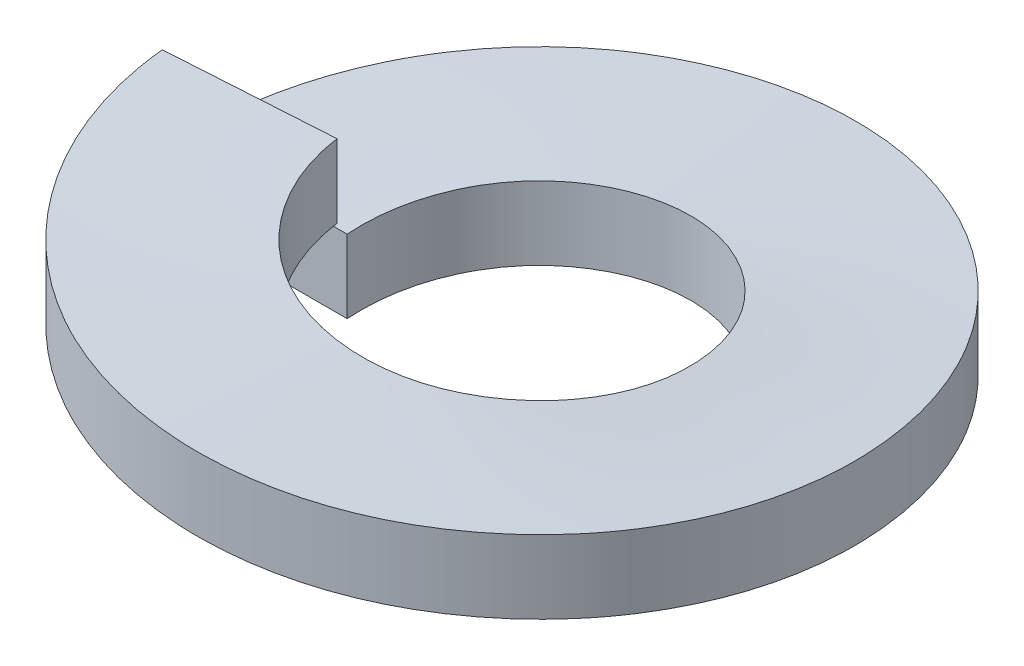
from build123d import *

# Parameters (mm, degrees)
SWEEP1_PITCH       = 0.615757576
SWEEP1_HEIGHT      = 0.6096
SWEEP1_RADIUS      = 2.286
SWEEP1_START_ANGLE = -90
SKETCH1_W          = 1.143
SKETCH1_H          = 0.508


with BuildPart() as part:
    # Sweep1: sweep along a helix
    with BuildLine() as sweep1_path:
        add(Helix(SWEEP1_PITCH, SWEEP1_HEIGHT, SWEEP1_RADIUS, center=(0, 0, 0), direction=(0, 1, 0), lefthand=True, mode=Mode.PRIVATE).rotate(Axis((0, 0, 0), (0, 1, 0)), SWEEP1_START_ANGLE))
    # Sketch1 → Sweep1 (sweep)
    with BuildSketch(Plane.XY):
        with Locations((-1.7145, 0.254)):
            Rectangle(SKETCH1_W, SKETCH1_H)
    sweep(path=sweep1_path.line, is_frenet=True)


solid = part.part
